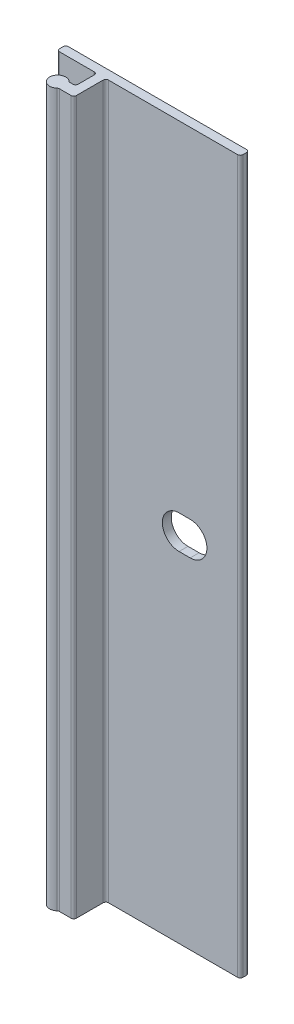
from build123d import *

# Parameters (mm, degrees)
BOSS_EXTRUDE1_DEPTH = 50.8
CUT_EXTRUDE1_DEPTH  = 2.27


with BuildPart() as part:
    # Sketch2 → Boss-Extrude1 (new body, symmetric)
    with BuildSketch(Plane(origin=(0, 0, 0), x_dir=(1, 0, 0), z_dir=(0, 1, 0))):
        with BuildLine():
            Line((-5.334, 0), (20.066, 0))
            ThreePointArc((20.066, 0), (20.335407684, -0.111592316), (20.447, -0.381))
            Line((20.447, -0.381), (20.447, -0.889))
            ThreePointArc((20.447, -0.889), (20.335407684, -1.158407684), (20.066, -1.27))
            Line((20.066, -1.27), (1.651, -1.27))
            ThreePointArc((1.651, -1.27), (1.381592316, -1.381592316), (1.27, -1.651))
            Line((1.27, -1.651), (1.27, -5.461))
            ThreePointArc((1.27, -5.461), (1.158407684, -5.730407684), (0.889, -5.842))
            Line((0.889, -5.842), (-0.76996875, -5.842))
            ThreePointArc((-0.76996875, -5.842), (-0.904672592, -5.866607134), (-1.021976563, -5.93725))
            ThreePointArc((-1.021976563, -5.93725), (-2.921, -5.08), (-1.021976563, -4.22275))
            ThreePointArc((-1.021976563, -4.22275), (-0.904672592, -4.293392866), (-0.76996875, -4.318))
            Line((-0.76996875, -4.318), (-0.381, -4.318))
            ThreePointArc((-0.381, -4.318), (-0.111592316, -4.206407684), (0, -3.937))
            Line((0, -3.937), (0, -1.651))
            ThreePointArc((0, -1.651), (-0.111592316, -1.381592316), (-0.381, -1.27))
            Line((-0.381, -1.27), (-5.334, -1.27))
            ThreePointArc((-5.334, -1.27), (-5.603407684, -1.158407684), (-5.715, -0.889))
            Line((-5.715, -0.889), (-5.715, -0.381))
            ThreePointArc((-5.715, -0.381), (-5.603407684, -0.111592316), (-5.334, 0))
        make_face()
    extrude(amount=BOSS_EXTRUDE1_DEPTH, both=True)

    # Sketch3 → Cut-Extrude1 (cut, through all)
    with BuildSketch(Plane.XY.offset(1.27)):
        with BuildLine():
            Line((11.71575, 2.38125), (13.30325, 2.38125))
            ThreePointArc((13.30325, 2.38125), (15.6845, 0), (13.30325, -2.38125))
            Line((13.30325, -2.38125), (11.71575, -2.38125))
            ThreePointArc((11.71575, -2.38125), (9.3345, 0), (11.71575, 2.38125))
        make_face()
    extrude(amount=-CUT_EXTRUDE1_DEPTH, mode=Mode.SUBTRACT)


solid = part.part
